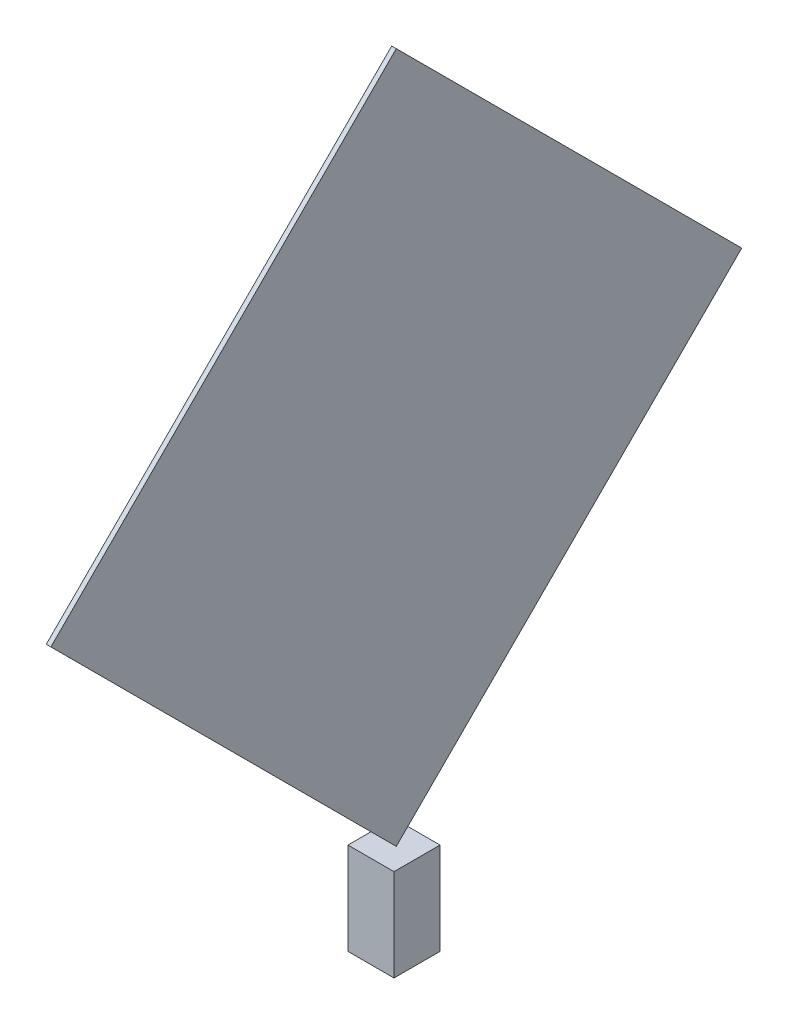
from build123d import *

# Parameters (mm, degrees)
SKETCH1_W                = 100
SKETCH1_H                = 100
BOSS_EXTRUDE1_DEPTH      = 200
BOSS_EXTRUDE2_DEPTH      = 5
BOSS_EXTRUDE2_DEPTH_BACK = 5


with BuildPart() as part:
    # Sketch1 → Boss-Extrude1 (new body)
    with BuildSketch(Plane(origin=(0, 0, 0), x_dir=(1, 0, 0), z_dir=(0, 1, 0))):
        with Locations((-1.807228916, 28.313253012)):
            Rectangle(SKETCH1_W, SKETCH1_H)
    extrude(amount=BOSS_EXTRUDE1_DEPTH)


with BuildPart() as body_2:
    # Sketch2 → Boss-Extrude2 (new body, two sides)
    with BuildSketch(Plane(origin=(-1.807228916, 0, 0), x_dir=(0, 0, -1), z_dir=(1, 0, 0))) as boss_extrude2_sk:
        Polygon((28.313253012, 200), (778.313253012, 950), (28.313253012, 1700), (-721.686746988, 950), align=None)
    extrude(amount=BOSS_EXTRUDE2_DEPTH)
    extrude(boss_extrude2_sk.sketch, amount=-BOSS_EXTRUDE2_DEPTH_BACK)


solid = Compound([part.part, body_2.part])
